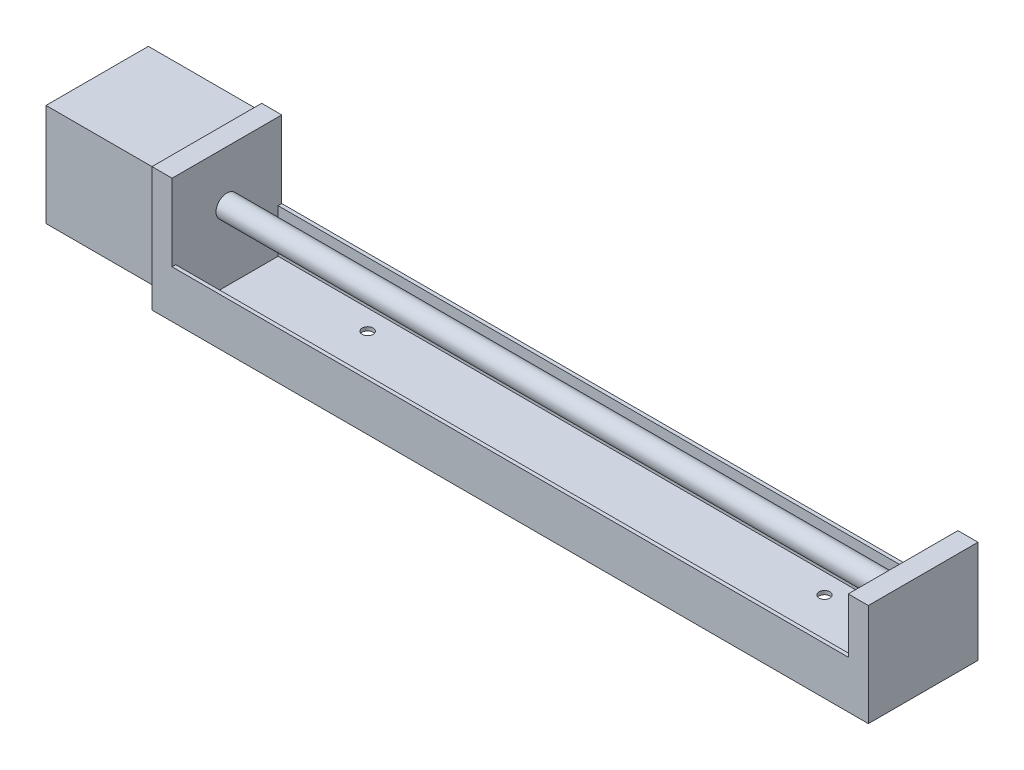
from build123d import *

# Parameters (mm, degrees)
SKETCH_1_W         = 30
SKETCH_1_H         = 28
EXTRUDE_1_DEPTH    = 14
SKETCH_2_W         = 30
SKETCH_2_H         = 34
EXTRUDE_2_DEPTH    = 5.5
EXTRUDE_3_DEPTH    = 185
SKETCH_4_W         = 30
SKETCH_4_H         = 28
EXTRUDE_4_DEPTH    = 5.5
SKETCH_5_R         = 3
EXTRUDE_5_DEPTH    = 190.5
SKETCH1_R          = 1.5
CUT_EXTRUDE1_DEPTH = 10


with BuildPart() as part:
    # 草图1 → 凸台-拉伸1 (new body, symmetric)
    with BuildSketch(Plane.XY):
        Rectangle(SKETCH_1_W, SKETCH_1_H)
    extrude(amount=EXTRUDE_1_DEPTH, both=True)

    # 草图2 → 凸台-拉伸2 (add)
    with BuildSketch(Plane(origin=(15, 0, 0), x_dir=(0, 0, -1), z_dir=(1, 0, 0))):
        with Locations((0, -2)):
            Rectangle(SKETCH_2_W, SKETCH_2_H)
    extrude(amount=EXTRUDE_2_DEPTH)

    # 草图3 → 凸台-拉伸3 (add)
    with BuildSketch(Plane(origin=(20.5, 0, 0), x_dir=(0, 0, -1), z_dir=(1, 0, 0))):
        Polygon((-15, -19), (15, -19), (15, -6), (14, -6), (14, -18), (-14, -18), (-14, -6), (-15, -6), align=None)
    extrude(amount=EXTRUDE_3_DEPTH)

    # 草图4 → 凸台-拉伸4 (add)
    with BuildSketch(Plane(origin=(205.5, 0, 0), x_dir=(0, 0, -1), z_dir=(1, 0, 0))):
        with Locations((0, -5)):
            Rectangle(SKETCH_4_W, SKETCH_4_H)
    extrude(amount=EXTRUDE_4_DEPTH)

    # 草图5 → 凸台-拉伸5 (add)
    with BuildSketch(Plane(origin=(211, 0, 0), x_dir=(0, 0, -1), z_dir=(1, 0, 0))):
        with Locations((0, 1)):
            Circle(SKETCH_5_R)
    extrude(amount=-EXTRUDE_5_DEPTH)

    # Sketch1 → Cut-Extrude1 (cut)
    with BuildSketch(Plane.XZ.offset(19)):
        with Locations((50.5, 8.5)):
            Circle(SKETCH1_R)
        with Locations((175.5, 8.5)):
            Circle(SKETCH1_R)
        with Locations((175.5, -8.5)):
            Circle(SKETCH1_R)
        with Locations((50.5, -8.5)):
            Circle(SKETCH1_R)
    extrude(amount=-CUT_EXTRUDE1_DEPTH, mode=Mode.SUBTRACT)


solid = part.part
